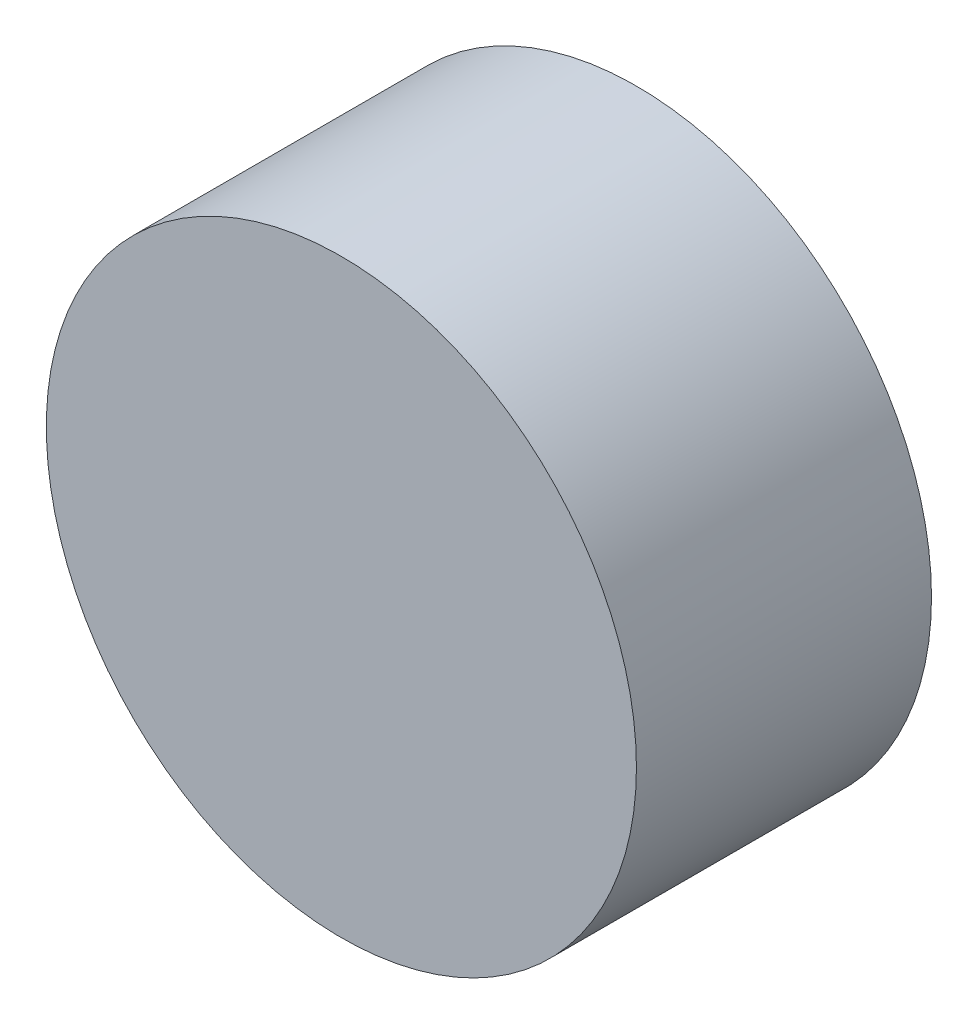
from build123d import *

# Parameters (mm, degrees)
SKETCH1_R           = 10
BOSS_EXTRUDE1_DEPTH = 10


with BuildPart() as part:
    # Sketch1 → Boss-Extrude1 (new body)
    with BuildSketch(Plane.XY):
        Circle(SKETCH1_R)
    extrude(amount=BOSS_EXTRUDE1_DEPTH)


solid = part.part
